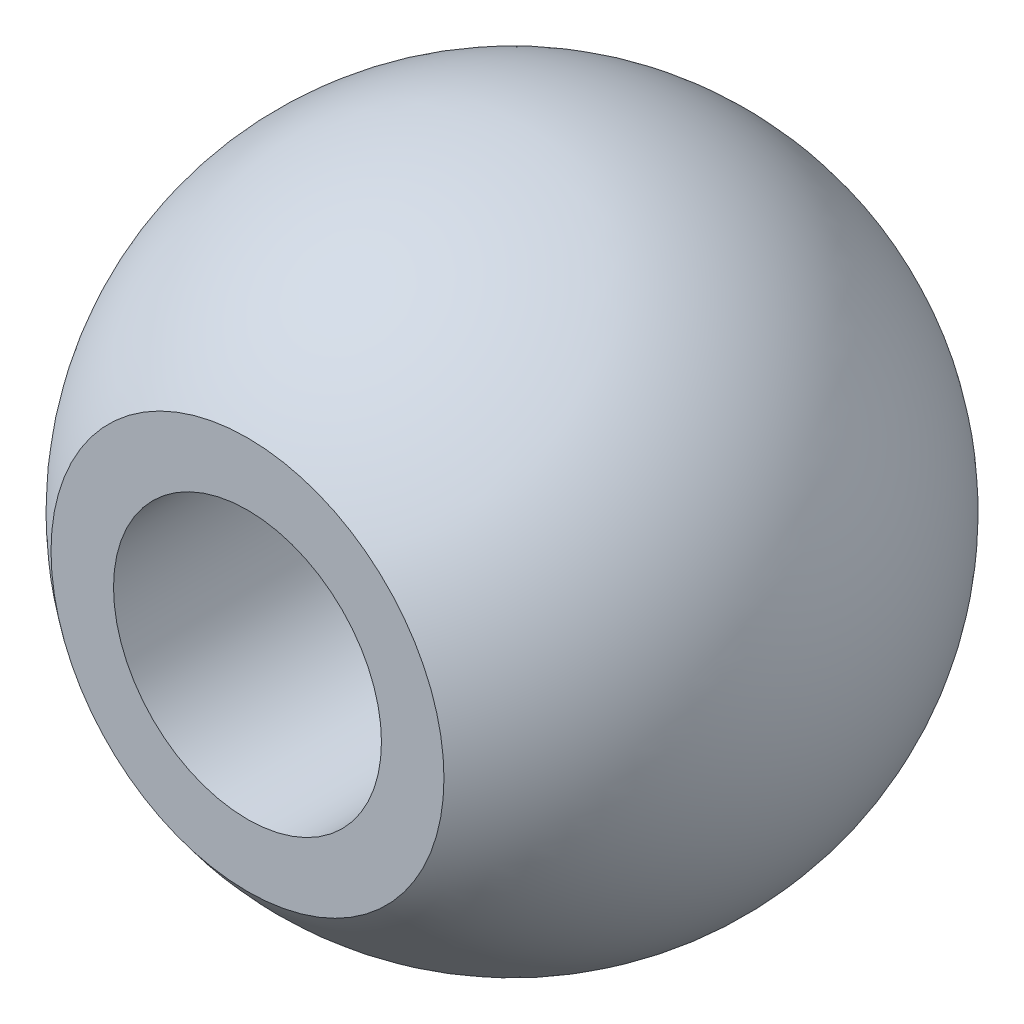
from build123d import *

# Parameters (mm, degrees)
CUT_EXTRUDE1_DEPTH      = 10
CUT_EXTRUDE1_DEPTH_BACK = 10
SKETCH2_R               = 1
CUT_EXTRUDE2_DEPTH      = 10
CUT_EXTRUDE2_DEPTH_BACK = 10
SKETCH3_OUTSIDE_W       = 8.624
SKETCH3_OUTSIDE_H       = 8.624
SKETCH3_OUTSIDE_W_2     = 6.592412756
SKETCH3_OUTSIDE_H_2     = 3.95


with BuildPart() as part:
    # Sketch1 → Revolve1 (revolve)
    with BuildSketch(Plane.XY):
        with BuildLine():
            Line((0, 2.46), (0, -2.46))
            ThreePointArc((0, -2.46), (-2.46, 0), (0, 2.46))
        make_face()
    revolve(axis=Axis((0, 2.46, 0), (0, -1, 0)))

    # Sketch2 → Cut-Extrude1 (cut, two sides: drawn at the far end of the back side and taken through both)
    with BuildSketch(Plane.XY.offset(-CUT_EXTRUDE1_DEPTH_BACK)):
        Circle(SKETCH2_R)
    extrude(amount=CUT_EXTRUDE1_DEPTH + CUT_EXTRUDE1_DEPTH_BACK, mode=Mode.SUBTRACT)

    # Sketch3 outside → Cut-Extrude2 (cut, two sides: drawn at the far end of the back side and taken through both)
    with BuildSketch(Plane(origin=(0, 0, 0), x_dir=(1, 0, 0), z_dir=(0, 1, 0)).offset(-CUT_EXTRUDE2_DEPTH_BACK)):
        Rectangle(SKETCH3_OUTSIDE_W, SKETCH3_OUTSIDE_H)
        Rectangle(SKETCH3_OUTSIDE_W_2, SKETCH3_OUTSIDE_H_2, mode=Mode.SUBTRACT)
    extrude(amount=CUT_EXTRUDE2_DEPTH + CUT_EXTRUDE2_DEPTH_BACK, mode=Mode.SUBTRACT)


solid = part.part
